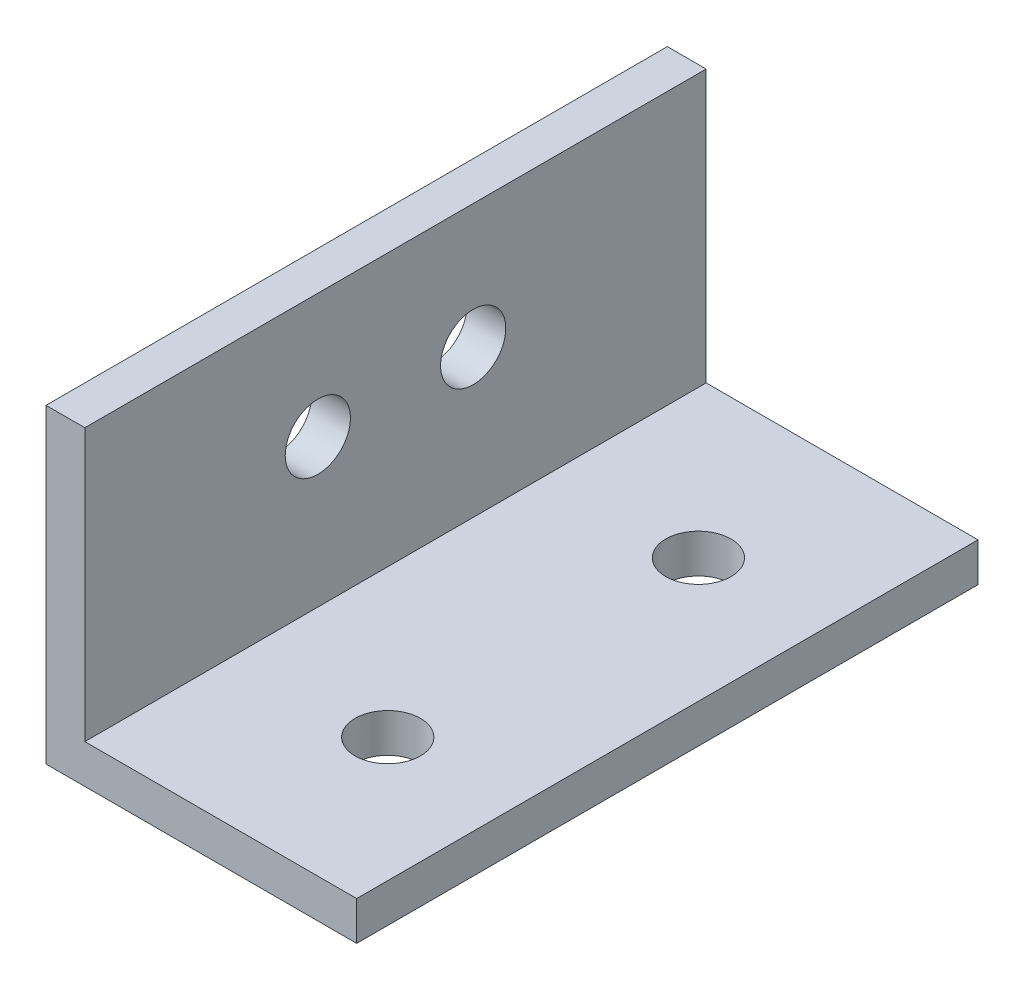
from build123d import *

# Parameters (mm, degrees)
SKETCH2_W           = 22.225
SKETCH2_H           = 3.175
SKETCH2_W_2         = 3.175
SKETCH2_H_2         = 22.225
BOSS_EXTRUDE1_DEPTH = 50.8
SKETCH3_R           = 2.667
CUT_EXTRUDE1_DEPTH  = 3.175
SKETCH4_R           = 2.667
CUT_EXTRUDE2_DEPTH  = 3.175


with BuildPart() as part:
    # Sketch2 → Boss-Extrude1 (new body)
    with BuildSketch(Plane.XY):
        with Locations((14.2875, 1.5875)):
            Rectangle(SKETCH2_W, SKETCH2_H)
        with Locations((1.5875, 1.5875)):
            Rectangle(SKETCH2_W_2, SKETCH2_H)
        with Locations((1.5875, 14.2875)):
            Rectangle(SKETCH2_W_2, SKETCH2_H_2)
    extrude(amount=BOSS_EXTRUDE1_DEPTH)

    # Sketch3 → Cut-Extrude1 (cut)
    with BuildSketch(Plane.ZY):
        with Locations((19.05, 15.24)):
            Circle(SKETCH3_R)
        with Locations((31.75, 15.24)):
            Circle(SKETCH3_R)
    extrude(amount=-CUT_EXTRUDE1_DEPTH, mode=Mode.SUBTRACT)

    # Sketch4 → Cut-Extrude2 (cut)
    with BuildSketch(Plane.XZ):
        with Locations((15.24, 38.1)):
            Circle(SKETCH4_R)
        with Locations((15.24, 12.7)):
            Circle(SKETCH4_R)
    extrude(amount=-CUT_EXTRUDE2_DEPTH, mode=Mode.SUBTRACT)


solid = part.part
